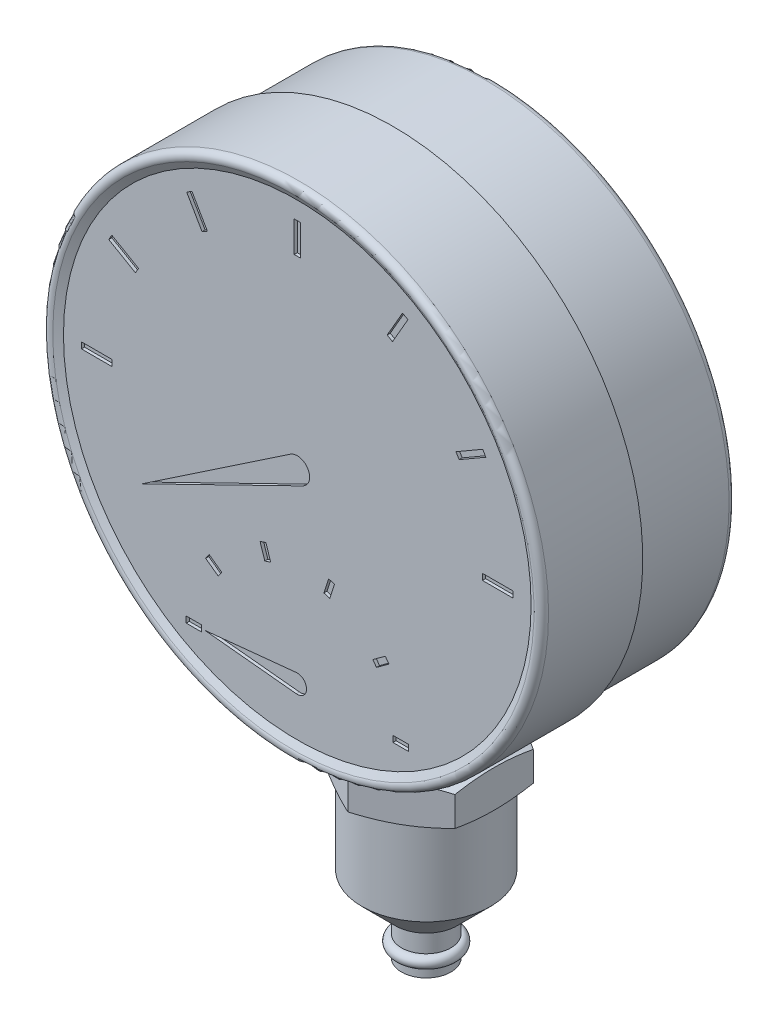
from build123d import *

# Parameters (mm, degrees)
ZAOBLIT1_R               = 1
SKICA2_W                 = 1
SKICA2_H                 = 5
ODEBRAT_VYSUNUT_M1_DEPTH = 0.5
KRUHOV_POLE1_COUNT       = 12
ODEBRAT_VYSUNUT_M2_DEPTH = 0.5
SKICA8_W                 = 2.5
SKICA8_H                 = 1
ODEBRAT_VYSUNUT_M5_DEPTH = 0.5
KRUHOV_POLE2_COUNT       = 6
KRUHOV_POLE2_ANGLE       = 180
SKICA9_W                 = 14
SKICA9_H                 = 14
P_IDAT_VYSUNUT_M1_DEPTH  = 7
SKICA11_OUTSIDE_W        = 113
SKICA11_OUTSIDE_H        = 72.915
ODEBRAT_VYSUNUT_M6_DEPTH = 39.44
SKICA12_R                = 0.9


with BuildPart() as part:
    # Skica1 → Rotovat1 (revolve)
    with BuildSketch(Plane(origin=(0, 0, 0), x_dir=(0, 0, -1), z_dir=(1, 0, 0)), mode=Mode.PRIVATE) as rotovat1_sk:
        Polygon((0, 40.5), (1.5, 37.901923789), (1.5, 0), (33, 0), (33, 39.5), (17, 39.5), (17, 40.5), align=None)
    revolve(rotovat1_sk.sketch.rotate(Axis((0, 0, 0), (0, 0, 1)), 90), axis=Axis((0, 0, 0), (0, 0, 1)))  # turned: the seam where the file's is

    # Zaoblit1
    zaoblit1_edges = [part.edges().sort_by_distance(p)[0] for p in [
        (40.5, 0, 0),
        (39.5, 0, -33),
    ]]
    fillet(zaoblit1_edges, radius=ZAOBLIT1_R)

    # Skica2 → Odebrat vysunutím1 (cut)
    with BuildSketch(Plane.XY.offset(-1.5)):
        with Locations((0, 32.5)):
            Rectangle(SKICA2_W, SKICA2_H)
    odebrat_vysunut_m1 = extrude(amount=-ODEBRAT_VYSUNUT_M1_DEPTH, mode=Mode.SUBTRACT)

    # Kruhové pole1: Odebrat vysunutím1 ×12 about axis, 5 skipped
    kruhov_pole1_axis = Axis((0, 0, 0), (0, 0, -1))
    add([odebrat_vysunut_m1.rotate(kruhov_pole1_axis, i * 360 / KRUHOV_POLE1_COUNT) for i in range(1, KRUHOV_POLE1_COUNT) if i not in (4, 5, 6, 7, 8)], mode=Mode.SUBTRACT)

    # Skica3 → Odebrat vysunutím2 (cut)
    with BuildSketch(Plane.XY.offset(-1.5)):
        with BuildLine():
            Line((-1.117070824, 1.658961354), (-25.11473671, -14.5))
            Line((-25.11473671, -14.5), (0.878167264, -1.796892388))
            ThreePointArc((0.878167264, -1.796892388), (1.732050808, 1), (-1.117070824, 1.658961354))
        make_face()
        with BuildLine():
            Line((-0.15, -28.507518844), (-15, -30))
            Line((-15, -30), (-0.15, -31.492481156))
            ThreePointArc((-0.15, -31.492481156), (1.5, -30), (-0.15, -28.507518844))
        make_face()
    extrude(amount=-ODEBRAT_VYSUNUT_M2_DEPTH, mode=Mode.SUBTRACT)

    # Skica8 → Odebrat vysunutím5 (cut)
    with BuildSketch(Plane.XY.offset(-1.5)):
        with Locations((-16.75, -30)):
            Rectangle(SKICA8_W, SKICA8_H)
    odebrat_vysunut_m5 = extrude(amount=-ODEBRAT_VYSUNUT_M5_DEPTH, mode=Mode.SUBTRACT)

    # Kruhové pole2: Odebrat vysunutím5 ×6 about axis
    kruhov_pole2_axis = Axis((0, -30, 0), (0, 0, -1))
    for i in range(1, KRUHOV_POLE2_COUNT):
        add(odebrat_vysunut_m5.rotate(kruhov_pole2_axis, i * KRUHOV_POLE2_ANGLE / (KRUHOV_POLE2_COUNT - 1)), mode=Mode.SUBTRACT)


with BuildPart() as body_2:
    # Skica9 → Přidat vysunutím1 (new body)
    with BuildSketch(Plane(origin=(0, -39.5, 0), x_dir=(1, 0, 0), z_dir=(0, 1, 0))):
        with Locations((0, 22.4)):
            Rectangle(SKICA9_W, SKICA9_H)
    extrude(amount=-P_IDAT_VYSUNUT_M1_DEPTH)

    # Skica10 → Rotovat3 (revolve)
    with BuildSketch(Plane(origin=(0, 0, 0), x_dir=(0, 0, -1), z_dir=(1, 0, 0)), mode=Mode.PRIVATE) as rotovat3_sk:
        Polygon((22.4, -46.5), (32.8, -46.5), (41.646877291, -49.72), (32.8, -52.94), (32.8, -66.54), (27.4, -71.94), (26.4, -71.94), (26.4, -75.54), (25.5, -75.54), (25.5, -77.54), (26.4, -77.54), (26.4, -78.94), (22.4, -78.94), align=None)
    revolve(rotovat3_sk.sketch.rotate(Axis((0, -46.5, -22.4), (0, -1, 0)), 180), axis=Axis((0, -46.5, -22.4), (0, -1, 0)))  # turned: the seam where the file's is

    # Skica11 outside → Odebrat vysunutím6 (cut)
    with BuildSketch(Plane.XZ.offset(78.94)):
        with Locations((0, -21.1895)):
            Rectangle(SKICA11_OUTSIDE_W, SKICA11_OUTSIDE_H)
        Polygon((11, -16.049147039), (0, -9.698294078), (-11, -16.049147039), (-11, -28.750852961), (0, -35.101705922), (11, -28.750852961), align=None, mode=Mode.SUBTRACT)
    extrude(amount=-ODEBRAT_VYSUNUT_M6_DEPTH, mode=Mode.SUBTRACT)


with BuildPart() as body_3:
    # Skica12 → Rotovat4 (revolve)
    with BuildSketch(Plane(origin=(0, 0, 0), x_dir=(0, 0, -1), z_dir=(1, 0, 0)), mode=Mode.PRIVATE) as rotovat4_sk:
        with Locations((26.5, -76.54)):
            Circle(SKICA12_R)
    revolve(rotovat4_sk.sketch.rotate(Axis((0, -75.54, -22.4), (0, -1, 0)), 180), axis=Axis((0, -75.54, -22.4), (0, -1, 0)))  # turned: the seam where the file's is


solid = Compound([part.part, body_2.part, body_3.part])
